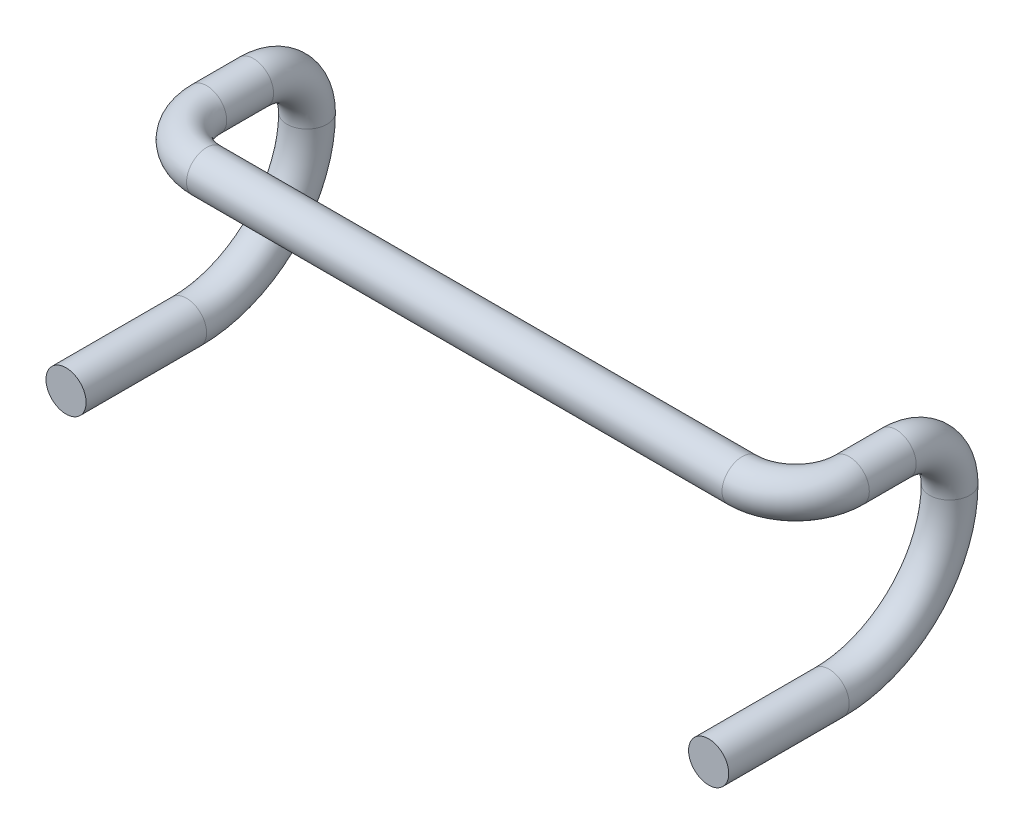
from build123d import *

# Parameters (mm, degrees)
SWEEP4_PROFILE_R = 15
SWEEP5_PROFILE_R = 15
SWEEP6_PROFILE_R = 15


with BuildPart() as part:
    # Sweep4: sweep along a path in Sketch1
    with BuildLine(Plane(origin=(0, 0, 0), x_dir=(1, 0, 0), z_dir=(0, 1, 0))) as sweep4_path:
        Line((0, 0), (-200, 0))
        ThreePointArc((-200, 0), (-228.284271247, 11.715728753), (-240, 40))
    # Sweep4 profile (on start of the path) → Sweep4 (sweep)
    with BuildSketch(Plane(origin=(0, 0, 0), x_dir=(0, 0, -1), z_dir=(-1, 0, 0))):
        Circle(SWEEP4_PROFILE_R)
    sweep4 = sweep(path=sweep4_path.line)

    # Sweep5: sweep along a path in Sketch2
    with BuildLine(Plane(origin=(-240, 0, 0), x_dir=(0, 0, -1), z_dir=(1, 0, 0))) as sweep5_path:
        Line((40, 0), (75, 0))
        ThreePointArc((75, 0), (103.284271247, -11.715728753), (115, -40))
        ThreePointArc((115, -40), (88.639610307, -103.639610307), (25, -130))
    # Sweep5 profile (on start of the path) → Sweep5 (sweep)
    with BuildSketch(Plane(origin=(-240, 0, -40), x_dir=(-1, 0, 0), z_dir=(0, 0, -1))):
        Circle(SWEEP5_PROFILE_R)
    sweep5 = sweep(path=sweep5_path.line)

    # Sweep6: sweep along a path in Sketch3
    with BuildLine(Plane(origin=(-240, 0, 0), x_dir=(0, 0, -1), z_dir=(1, 0, 0))) as sweep6_path:
        Line((25, -130), (-65, -130))
    # Sweep6 profile (on start of the path) → Sweep6 (sweep)
    with BuildSketch(Plane(origin=(-240, -130, -25), x_dir=(1, 0, 0), z_dir=(0, 0, 1))):
        Circle(SWEEP6_PROFILE_R)
    sweep6 = sweep(path=sweep6_path.line)

    # Mirror1: Sweep4, Sweep5, Sweep6 across plane
    add(sweep4.mirror(Plane(origin=(0, 0, 0), x_dir=(0, 0, 1), z_dir=(1, 0, 0))))
    add(sweep5.mirror(Plane(origin=(0, 0, 0), x_dir=(0, 0, 1), z_dir=(1, 0, 0))))
    add(sweep6.mirror(Plane(origin=(0, 0, 0), x_dir=(0, 0, 1), z_dir=(1, 0, 0))))


solid = part.part
